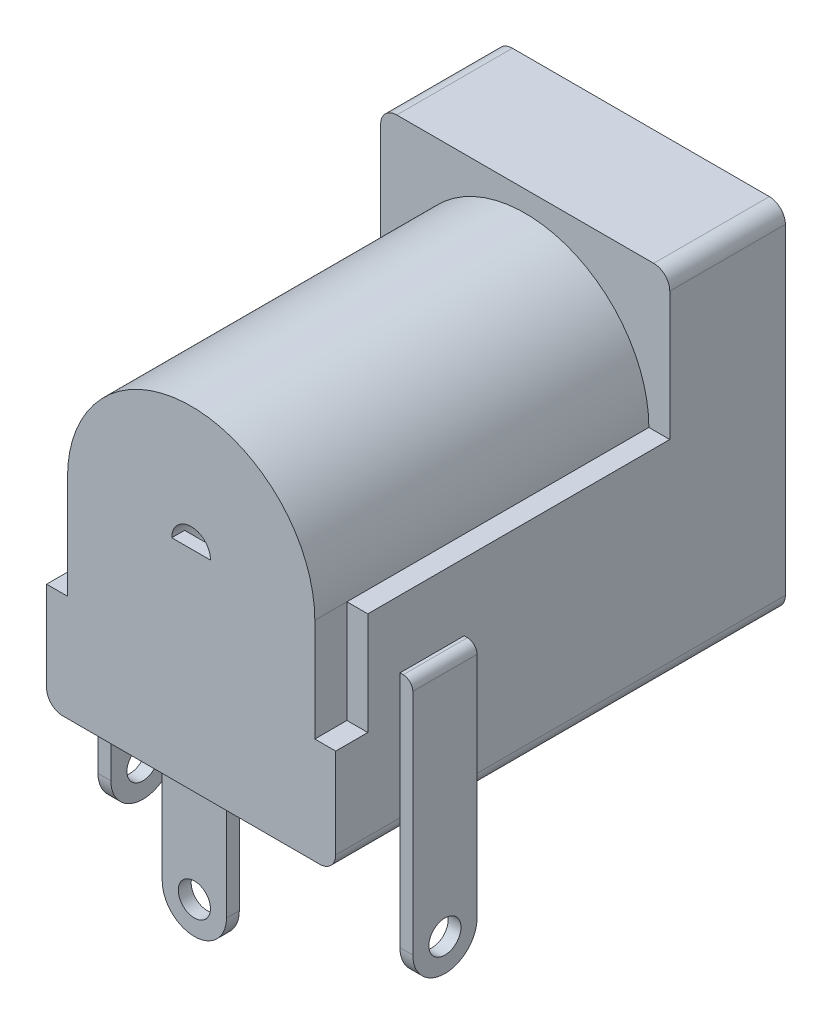
from build123d import *

# Parameters (mm, degrees)
SKETCH_1_R               = 3.2
EXTRUDE_1_DEPTH          = 14
CUT_EXTRUDE_1_DEPTH      = 1
CUT_EXTRUDE_1_DEPTH_BACK = 10.4
SKETCH_3_W               = 0.65
SKETCH_3_H               = 3.2
CUT_EXTRUDE_2_DEPTH      = 1
SKETCH_4_W               = 0.4
SKETCH_4_H               = 2
EXTRUDE_2_DEPTH          = 4
EXTRUDE_2_2_DEPTH        = 4
SKETCH_4_W_2             = 2
SKETCH_4_H_2             = 0.4
EXTRUDE_2_3_DEPTH        = 4
EXTRUDE_3_DEPTH          = 2
EXTRUDE_4_DEPTH          = 2
SKETCH_8_R               = 3.2
SKETCH_8_R_2             = 0.603563731
EXTRUDE_5_DEPTH          = 2
SKETCH_9_R               = 0.5
CUT_EXTRUDE_3_DEPTH      = 10.8
SKETCH_10_R              = 0.5
CUT_EXTRUDE_4_DEPTH      = 2


with BuildPart() as part:
    # 草图1 → 凸台-拉伸1 (new body)
    with BuildSketch(Plane.XY):
        with BuildLine():
            Line((-4, 5.5), (4, 5.5))
            ThreePointArc((4, 5.5), (4.353553391, 5.353553391), (4.5, 5))
            Line((4.5, 5), (4.5, -5))
            ThreePointArc((4.5, -5), (4.353553391, -5.353553391), (4, -5.5))
            Line((4, -5.5), (-4, -5.5))
            ThreePointArc((-4, -5.5), (-4.353553391, -5.353553391), (-4.5, -5))
            Line((-4.5, -5), (-4.5, 5))
            ThreePointArc((-4.5, 5), (-4.353553391, 5.353553391), (-4, 5.5))
        make_face()
        with Locations((0, 1)):
            Circle(SKETCH_1_R, mode=Mode.SUBTRACT)
    extrude(amount=EXTRUDE_1_DEPTH)

    # 草图2 → 切除-拉伸1 (cut, two sides)
    with BuildSketch(Plane.XY.offset(14)) as cut_extrude_1_sk:
        with BuildLine():
            ThreePointArc((-3.85, 1), (0, 4.85), (3.85, 1))
            Line((3.85, 1), (4.5, 1))
            Line((4.5, 1), (4.5, 5))
            ThreePointArc((4.5, 5), (4.353553391, 5.353553391), (4, 5.5))
            Line((4, 5.5), (-4, 5.5))
            ThreePointArc((-4, 5.5), (-4.353553391, 5.353553391), (-4.5, 5))
            Line((-4.5, 5), (-4.5, 1))
            Line((-4.5, 1), (-3.85, 1))
        make_face()
    extrude(amount=CUT_EXTRUDE_1_DEPTH, mode=Mode.SUBTRACT)
    extrude(cut_extrude_1_sk.sketch, amount=-CUT_EXTRUDE_1_DEPTH_BACK, mode=Mode.SUBTRACT)

    # 草图3 → 切除-拉伸2 (cut)
    with BuildSketch(Plane.XY.offset(14)):
        with Locations((-4.175, -0.6)):
            Rectangle(SKETCH_3_W, SKETCH_3_H)
        with Locations((4.175, -0.6)):
            Rectangle(SKETCH_3_W, SKETCH_3_H)
    extrude(amount=-CUT_EXTRUDE_2_DEPTH, mode=Mode.SUBTRACT)



with BuildPart() as body_2:
    # 草图4 → 凸台-拉伸2 (new body)
    with BuildSketch(Plane(origin=(0, -5.5, 0), x_dir=(-1, 0, 0), z_dir=(0, -1, 0))):
        with Locations((4.7, -11)):
            Rectangle(SKETCH_4_W, SKETCH_4_H)
    extrude(amount=EXTRUDE_2_DEPTH)


with BuildPart() as body_3:
    # 草图4 → Extrude 2 2 (new body)
    with BuildSketch(Plane(origin=(0, -5.5, 0), x_dir=(-1, 0, 0), z_dir=(0, -1, 0))):
        with Locations((-4.7, -11)):
            Rectangle(SKETCH_4_W, SKETCH_4_H)
    extrude(amount=EXTRUDE_2_2_DEPTH)


with BuildPart() as body_4:
    # 草图4 → Extrude 2 3 (new body)
    with BuildSketch(Plane(origin=(0, -5.5, 0), x_dir=(-1, 0, 0), z_dir=(0, -1, 0))):
        with Locations((0, -13.7)):
            Rectangle(SKETCH_4_W_2, SKETCH_4_H_2)
    extrude(amount=EXTRUDE_2_3_DEPTH)


with BuildPart() as part_1:
    add(part.part)

    add(body_2.part)  # 凸台-拉伸3 merges body 2

    add(body_3.part)  # 凸台-拉伸3 merges body 3
    # 草图5 → 凸台-拉伸3 (add)
    with BuildSketch(Plane(origin=(0, 0, 10), x_dir=(-1, 0, 0), z_dir=(0, 0, -1))):
        with BuildLine():
            Line((4.5, -5.5), (4.5, -1.092241159))
            Line((4.5, -1.092241159), (4.6, -1.092241159))
            ThreePointArc((4.6, -1.092241159), (4.812132034, -1.180109124), (4.9, -1.392241159))
            Line((4.9, -1.392241159), (4.9, -5.5))
            Line((4.9, -5.5), (4.5, -5.5))
        make_face()
        with BuildLine():
            Line((-4.9, -1.392241159), (-4.9, -5.5))
            Line((-4.9, -5.5), (-4.5, -5.5))
            Line((-4.5, -5.5), (-4.5, -1.092241159))
            Line((-4.5, -1.092241159), (-4.6, -1.092241159))
            ThreePointArc((-4.6, -1.092241159), (-4.812132034, -1.180109124), (-4.9, -1.392241159))
        make_face()
    extrude(amount=-EXTRUDE_3_DEPTH)


    add(body_4.part)  # 凸台-拉伸4 merges body 4
    # 草图7 → 凸台-拉伸4 (add)
    with BuildSketch(Plane.ZY.offset(1)):
        with BuildLine():
            Line((14, -5.5), (14, 1))
            Line((14, 1), (13.6, 1))
            ThreePointArc((13.6, 1), (13.812132034, 0.912132034), (13.9, 0.7))
            Line((13.9, 0.7), (13.9, -5.5))
            Line((13.9, -5.5), (14, -5.5))
        make_face()
    extrude(amount=-EXTRUDE_4_DEPTH)

    # 草图8 → 凸台-拉伸5 (add)
    with BuildSketch(Plane.XY.offset(14)):
        with Locations((0, 1)):
            Circle(SKETCH_8_R)
        with Locations((0, 1)):
            Circle(SKETCH_8_R_2, mode=Mode.SUBTRACT)
    extrude(amount=-EXTRUDE_5_DEPTH)

    # 草图9 → 切除-拉伸3 (cut, through all)
    with BuildSketch(Plane.ZY.offset(4.9)):
        with Locations((11, -8.5)):
            Circle(SKETCH_9_R)
        with BuildLine():
            Line((10, -8.5), (10, -9.805302044))
            Line((10, -9.805302044), (12, -9.805302044))
            Line((12, -9.805302044), (12, -8.5))
            ThreePointArc((12, -8.5), (11, -9.5), (10, -8.5))
        make_face()
    extrude(amount=-CUT_EXTRUDE_3_DEPTH, mode=Mode.SUBTRACT)

    # 草图10 → 切除-拉伸4 (cut)
    with BuildSketch(Plane.XY.offset(13.9)):
        with Locations((0, -8.5)):
            Circle(SKETCH_10_R)
        with BuildLine():
            Line((-1, -8.5), (-1, -10.359825608))
            Line((-1, -10.359825608), (1, -10.359825608))
            Line((1, -10.359825608), (1, -8.5))
            ThreePointArc((1, -8.5), (0, -9.5), (-1, -8.5))
        make_face()
    extrude(amount=-CUT_EXTRUDE_4_DEPTH, mode=Mode.SUBTRACT)


solid = part_1.part
